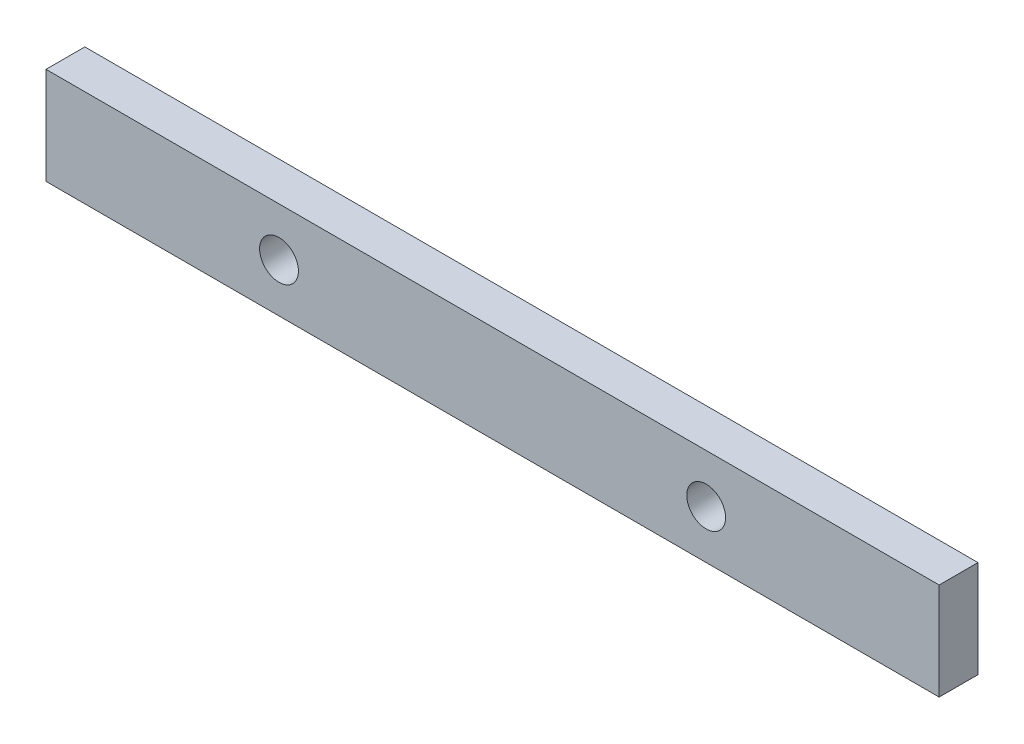
from build123d import *

# Parameters (mm, degrees)
SKETCH1_W           = 460
SKETCH1_H           = 50
SKETCH1_R           = 10
BOSS_EXTRUDE1_DEPTH = 20


with BuildPart() as part:
    # Sketch1 → Boss-Extrude1 (new body)
    with BuildSketch(Plane.XY):
        Rectangle(SKETCH1_W, SKETCH1_H)
        with Locations((110, 0)):
            Circle(SKETCH1_R, mode=Mode.SUBTRACT)
        with Locations((-110, 0)):
            Circle(SKETCH1_R, mode=Mode.SUBTRACT)
    extrude(amount=BOSS_EXTRUDE1_DEPTH)


solid = part.part
